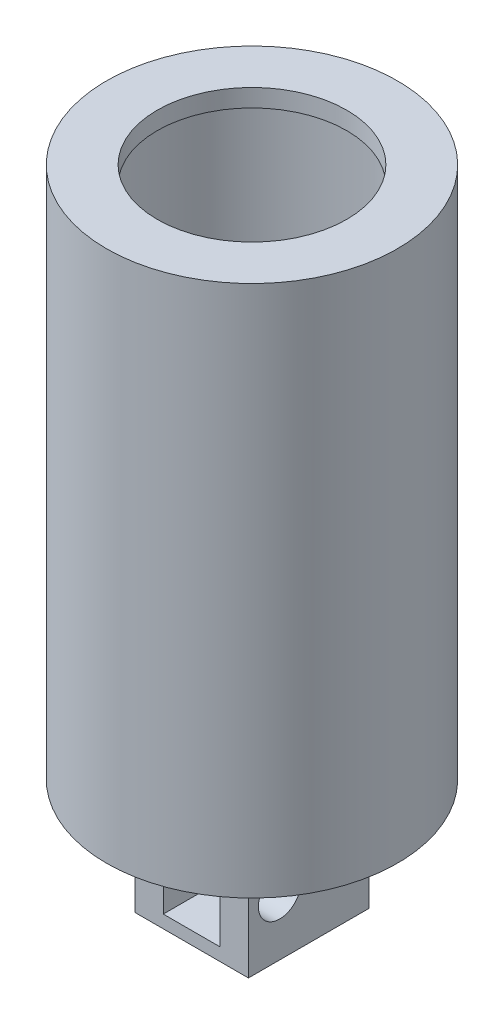
from build123d import *

# Parameters (mm, degrees)
SKETCH2_R           = 10.25
BOSS_EXTRUDE1_DEPTH = 1
SKETCH3_W           = 8
SKETCH3_H           = 8.5
BOSS_EXTRUDE2_DEPTH = 8
CUT_EXTRUDE1_START  = 4
SKETCH4_R           = 1.5
CUT_EXTRUDE1_DEPTH  = 2
SKETCH4_3_R         = 1.5
CUT_EXTRUDE3_DEPTH  = 8


with BuildPart() as part:
    # Sketch1 → Revolve1 (revolve)
    with BuildSketch(Plane.XY):
        Polygon((-6.674207745, -1.25), (-6.674207745, 0), (-10.25, 0), (-10.25, -36.5), (-9, -36.5), (-9, -1.25), align=None)
    revolve(axis=Axis((0, 9.278019649, 0), (0, -1, 0)))

    # Sketch2 → Boss-Extrude1 (add)
    with BuildSketch(Plane.XZ.offset(36.5)):
        Circle(SKETCH2_R)
    extrude(amount=BOSS_EXTRUDE1_DEPTH)

    # Sketch3 → Boss-Extrude2 (add)
    with BuildSketch(Plane.XZ.offset(37.5)):
        Rectangle(SKETCH3_W, SKETCH3_H)
    extrude(amount=BOSS_EXTRUDE2_DEPTH)

    # Sketch4 → Cut-Extrude1 (cut, symmetric)
    with BuildSketch(Plane(origin=(4, 0, -0.2768318), x_dir=(0, 0, 1), z_dir=(-1, 0, 0)).offset(CUT_EXTRUDE1_START)):
        with BuildLine():
            Line((4.5268318, -44.6), (4.5268318, -38.4))
            Line((4.5268318, -38.4), (-0.4731682, -38.4))
            ThreePointArc((-0.4731682, -38.4), (-3.5731682, -41.5), (-0.4731682, -44.6))
            Line((-0.4731682, -44.6), (4.5268318, -44.6))
        make_face()
        with Locations((2.3268318, -41.5)):
            Circle(SKETCH4_R, mode=Mode.SUBTRACT)
    extrude(amount=CUT_EXTRUDE1_DEPTH, both=True, mode=Mode.SUBTRACT)

    # Sketch4_3 → Cut-Extrude3 (cut)
    with BuildSketch(Plane(origin=(4, 0, -0.2768318), x_dir=(0, 0, 1), z_dir=(-1, 0, 0))):
        with Locations((2.3268318, -41.5)):
            Circle(SKETCH4_3_R)
    extrude(amount=CUT_EXTRUDE3_DEPTH, mode=Mode.SUBTRACT)


solid = part.part
